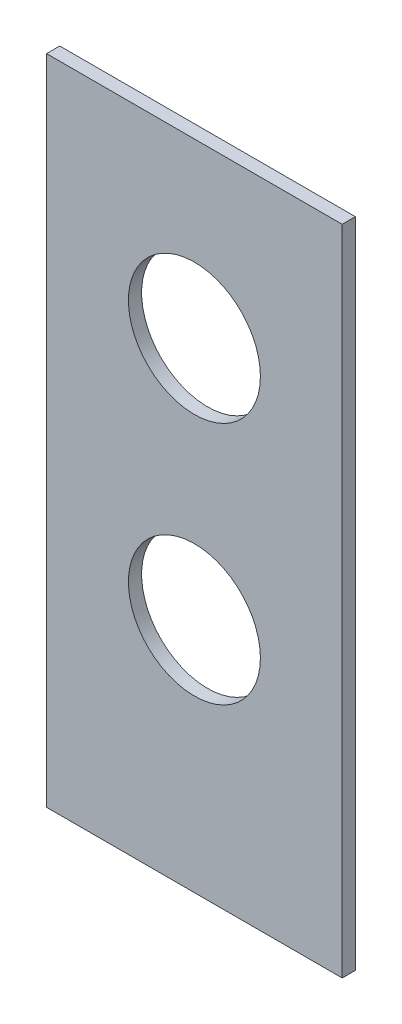
from build123d import *

# Parameters (mm, degrees)
SKETCH1_W           = 56.891165124
SKETCH1_H           = 125.605714286
BOSS_EXTRUDE1_DEPTH = 2.54
CUT_EXTRUDE1_REACH  = 4.54
SKETCH2_R           = 12.7


with BuildPart() as part:
    # Sketch1 → Boss-Extrude1 (new body)
    with BuildSketch(Plane.XY):
        Rectangle(SKETCH1_W, SKETCH1_H)
    extrude(amount=BOSS_EXTRUDE1_DEPTH)

    # Sketch2 → Cut-Extrude1 (cut, up to next)
    with BuildSketch(Plane.XY.offset(2.54), mode=Mode.PRIVATE) as cut_extrude1_sk1:
        with Locations((0, 29.58)):
            Circle(SKETCH2_R)
    cut_extrude1_tool1 = extrude(cut_extrude1_sk1.sketch, amount=-CUT_EXTRUDE1_REACH, mode=Mode.PRIVATE) & part.part
    add(cut_extrude1_tool1.solids().sort_by_distance((0, 29.58, 2.54))[0], mode=Mode.SUBTRACT)
    # Sketch2 → Cut-Extrude1 (cut, up to next)
    with BuildSketch(Plane.XY.offset(2.54), mode=Mode.PRIVATE) as cut_extrude1_sk2:
        with Locations((0, -17.34)):
            Circle(SKETCH2_R)
    cut_extrude1_tool2 = extrude(cut_extrude1_sk2.sketch, amount=-CUT_EXTRUDE1_REACH, mode=Mode.PRIVATE) & part.part
    add(cut_extrude1_tool2.solids().sort_by_distance((0, -17.34, 2.54))[0], mode=Mode.SUBTRACT)


solid = part.part
